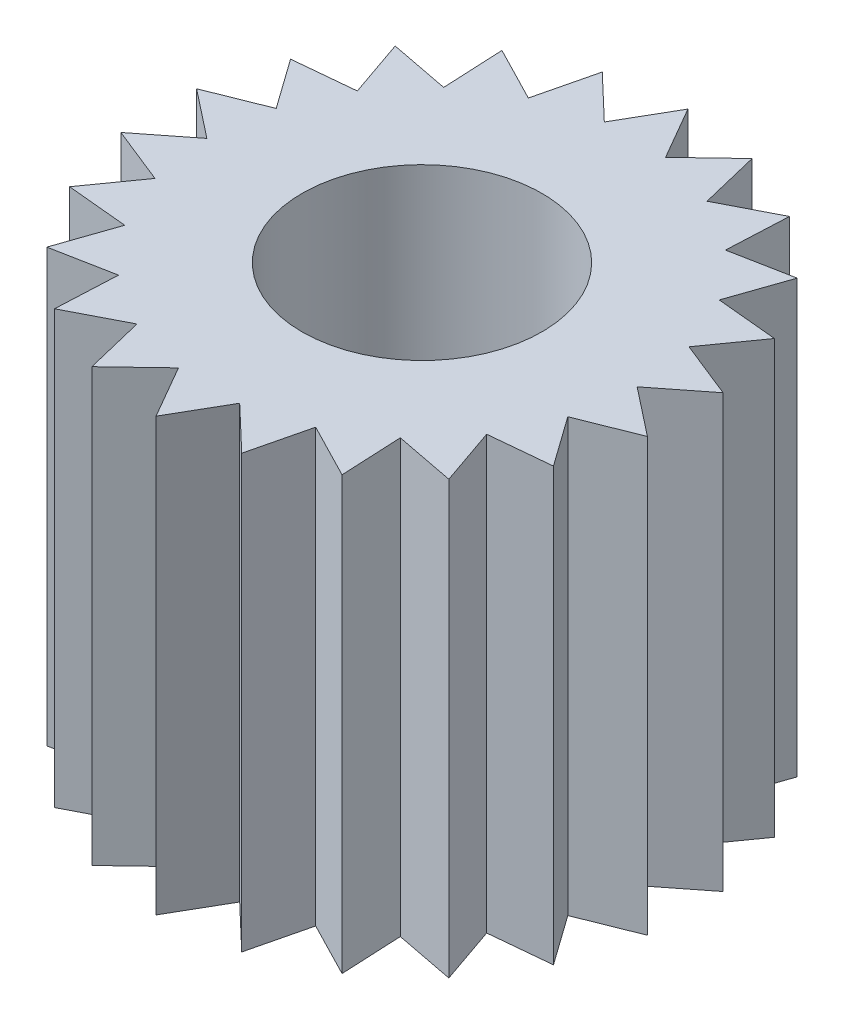
from build123d import *

# Parameters (mm, degrees)
SKETCH1_R           = 2.5
BOSS_EXTRUDE1_DEPTH = 9


with BuildPart() as part:
    # Sketch1 → Boss-Extrude1 (new body)
    with BuildSketch(Plane(origin=(0, 0, 0), x_dir=(1, 0, 0), z_dir=(0, 1, 0))):
        Polygon((1.561153305, 5.316799887), (0.637864624, 4.436445909), (0, 5.541259846), (-0.637864624, 4.436445909), (-1.561153305, 5.316799887), (-1.861917874, 4.077031446), (-2.995831253, 4.661604422), (-2.935129611, 3.387320142), (-4.18780477, 3.62875349), (-3.770554603, 2.423188306), (-5.040507251, 2.301922531), (-4.300511685, 1.262744164), (-5.484857811, 0.788603499), (-4.482066887, 0), (-5.484857811, -0.788603499), (-4.300511685, -1.262744164), (-5.040507251, -2.301922531), (-3.770554603, -2.423188306), (-4.18780477, -3.62875349), (-2.935129611, -3.387320142), (-2.941213111, -3.515028519), (-2.995831253, -4.661604422), (-1.861917874, -4.077031446), (-1.561153305, -5.316799887), (-0.637864624, -4.436445909), (0, -5.541259846), (0.637864624, -4.436445909), (1.561153305, -5.316799887), (1.861917874, -4.077031446), (2.995831253, -4.661604422), (2.935129611, -3.387320142), (4.18780477, -3.62875349), (3.770554603, -2.423188306), (5.040507251, -2.301922531), (4.300511685, -1.262744164), (5.484857811, -0.788603499), (4.482066887, 0), (5.484857811, 0.788603499), (4.300511685, 1.262744164), (5.040507251, 2.301922531), (3.770554603, 2.423188306), (4.18780477, 3.62875349), (3.001290377, 3.400071585), (2.935129611, 3.387320142), (2.941213111, 3.515028519), (2.995831253, 4.661604422), (1.861917874, 4.077031446), align=None)
        Circle(SKETCH1_R, mode=Mode.SUBTRACT)
    extrude(amount=BOSS_EXTRUDE1_DEPTH)


solid = part.part
